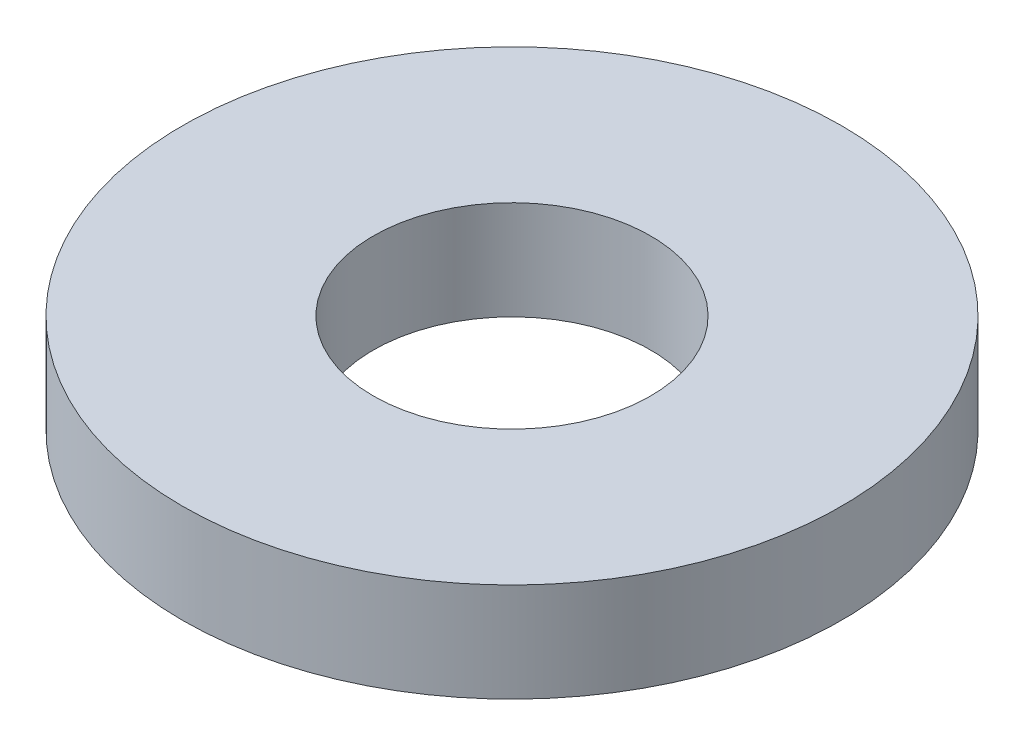
from build123d import *

# Parameters (mm, degrees)
SKETCH1_R      = 15.875
SKETCH1_R_2    = 6.6802
EXTRUDE1_DEPTH = 4.7625


with BuildPart() as part:
    # Sketch1 → Extrude1 (new body)
    with BuildSketch(Plane(origin=(0, 0, 0), x_dir=(1, 0, 0), z_dir=(0, 1, 0))):
        Circle(SKETCH1_R)
        Circle(SKETCH1_R_2, mode=Mode.SUBTRACT)
    extrude(amount=-EXTRUDE1_DEPTH)


solid = part.part
